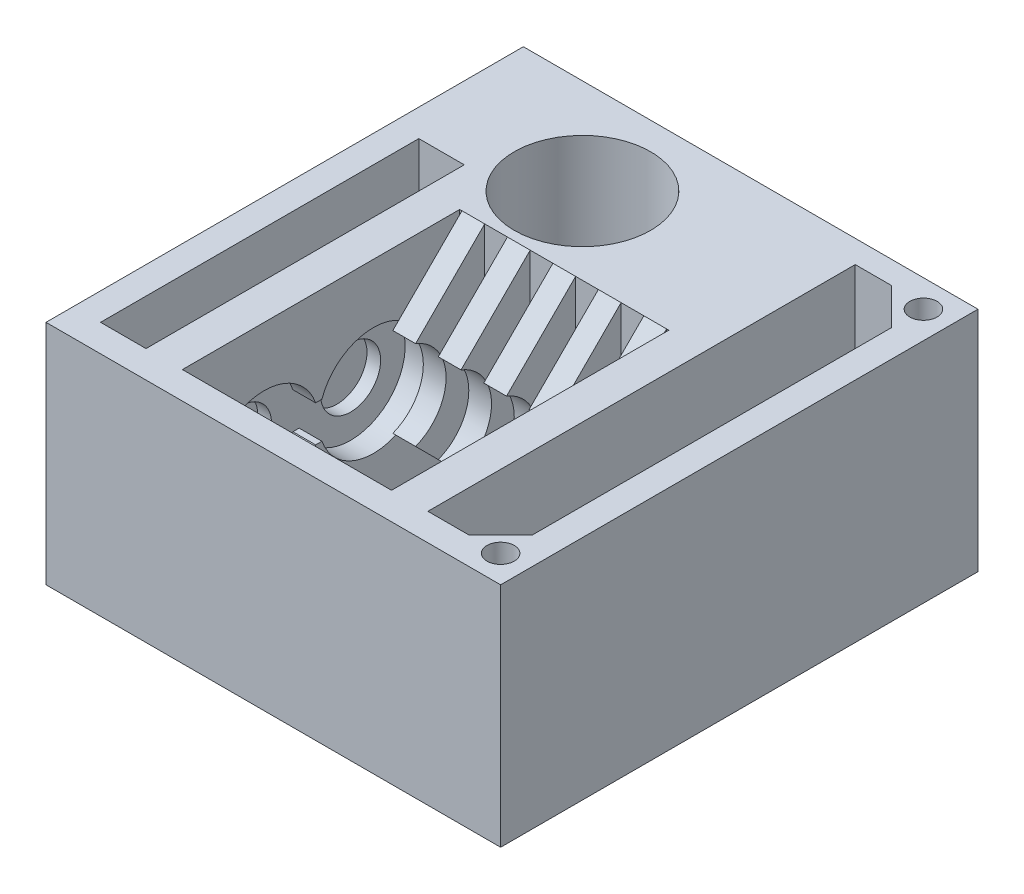
from build123d import *

# Parameters (mm, degrees)
SKETCH2_W           = 100
SKETCH2_H           = 105
BOSS_EXTRUDE1_DEPTH = 50
CUT_EXTRUDE1_REACH  = 52
SKETCH3_R           = 15
CUT_EXTRUDE3_REACH  = 52
SKETCH5_W           = 16
SKETCH5_H           = 80
SKETCH5_W_2         = 10
SKETCH5_H_2         = 70
CUT_EXTRUDE4_DEPTH  = 31
SKETCH7_R           = 6.6
BOSS_EXTRUDE2_DEPTH = 3
CUT_EXTRUDE7_REACH  = 52
SKETCH11_W          = 16
SKETCH11_H          = 14
CUT_EXTRUDE5_REACH  = 52
SKETCH8_W           = 46
SKETCH8_H           = 61
SKETCH9_R           = 1.75
CUT_EXTRUDE8_DEPTH  = 3
SKETCH13_W          = 20
SKETCH13_H          = 19
CUT_EXTRUDE9_DEPTH  = 30
BOSS_EXTRUDE4_DEPTH = 5
LPATTERN10_COUNT    = 5
LPATTERN10_PITCH    = 10
BOSS_EXTRUDE5_DEPTH = 5
LPATTERN11_COUNT    = 4
LPATTERN11_PITCH    = 10
BOSS_EXTRUDE6_DEPTH = 50
SKETCH20_R          = 3
CUT_EXTRUDE13_DEPTH = 50


with BuildPart() as part:
    # Sketch2 → Boss-Extrude1 (new body)
    with BuildSketch(Plane(origin=(0, 0, 0), x_dir=(1, 0, 0), z_dir=(0, 1, 0))):
        Rectangle(SKETCH2_W, SKETCH2_H)
    extrude(amount=BOSS_EXTRUDE1_DEPTH)

    # Sketch3 → Cut-Extrude1 (cut, up to next)
    with BuildSketch(Plane(origin=(0, 50, 0), x_dir=(1, 0, 0), z_dir=(0, 1, 0)), mode=Mode.PRIVATE) as cut_extrude1_sk1:
        with Locations((-16.005435425, 31.5)):
            Circle(SKETCH3_R)
    cut_extrude1_tool1 = extrude(cut_extrude1_sk1.sketch, amount=-CUT_EXTRUDE1_REACH, mode=Mode.PRIVATE) & part.part
    add(cut_extrude1_tool1.solids().sort_by_distance((-16.005435, 50, -31.5))[0], mode=Mode.SUBTRACT)

    # Sketch5 → Cut-Extrude3 (cut, up to next)
    with BuildSketch(Plane(origin=(0, 50, 0), x_dir=(1, 0, 0), z_dir=(0, 1, 0)), mode=Mode.PRIVATE) as cut_extrude3_sk1:
        with Locations((36, -6.5)):
            Rectangle(SKETCH5_W, SKETCH5_H)
    cut_extrude3_tool1 = extrude(cut_extrude3_sk1.sketch, amount=-CUT_EXTRUDE3_REACH, mode=Mode.PRIVATE) & part.part
    add(cut_extrude3_tool1.solids().sort_by_distance((36, 50, 6.5))[0], mode=Mode.SUBTRACT)
    # Sketch5 → Cut-Extrude3 (cut, up to next)
    with BuildSketch(Plane(origin=(0, 50, 0), x_dir=(1, 0, 0), z_dir=(0, 1, 0)), mode=Mode.PRIVATE) as cut_extrude3_sk2:
        with Locations((-39, -11.5)):
            Rectangle(SKETCH5_W_2, SKETCH5_H_2)
    cut_extrude3_tool2 = extrude(cut_extrude3_sk2.sketch, amount=-CUT_EXTRUDE3_REACH, mode=Mode.PRIVATE) & part.part
    add(cut_extrude3_tool2.solids().sort_by_distance((-39, 50, 11.5))[0], mode=Mode.SUBTRACT)

    # Sketch6 → Cut-Extrude4 (cut)
    with BuildSketch(Plane(origin=(28, 0, 0), x_dir=(0, 0, -1), z_dir=(1, 0, 0))):
        with BuildLine():
            Line((-17.186291501, 29), (-15.813708499, 29))
            ThreePointArc((-15.813708499, 29), (7.5, 25), (-15.813708499, 21))
            Line((-15.813708499, 21), (-17.186291501, 21))
            ThreePointArc((-17.186291501, 21), (-40.5, 25), (-17.186291501, 29))
        make_face()
    cut_extrude4 = extrude(amount=-CUT_EXTRUDE4_DEPTH, mode=Mode.SUBTRACT)

    # Sketch7 → Boss-Extrude2 (add)
    with BuildSketch(Plane(origin=(28, 0, 0), x_dir=(0, 0, -1), z_dir=(1, 0, 0))):
        with BuildLine():
            Line((-17.186291501, 21), (-15.813708499, 21))
            ThreePointArc((-15.813708499, 21), (7.5, 25), (-15.813708499, 29))
            Line((-15.813708499, 29), (-17.186291501, 29))
            ThreePointArc((-17.186291501, 29), (-40.5, 25), (-17.186291501, 21))
        make_face()
        with Locations((-28.5, 25)):
            Circle(SKETCH7_R, mode=Mode.SUBTRACT)
        with Locations((-4.5, 25)):
            Circle(SKETCH7_R, mode=Mode.SUBTRACT)
    boss_extrude2 = extrude(amount=-BOSS_EXTRUDE2_DEPTH)

    # Mirror1: Cut-Extrude4, Boss-Extrude2 across plane
    add(cut_extrude4.mirror(Plane(origin=(-3, 0, 0), x_dir=(0, 0, 1), z_dir=(1, 0, 0))), mode=Mode.SUBTRACT)
    add(boss_extrude2.mirror(Plane(origin=(-3, 0, 0), x_dir=(0, 0, 1), z_dir=(1, 0, 0))))

    # Sketch11 → Cut-Extrude7 (cut, up to next)
    with BuildSketch(Plane(origin=(0, 50, 0), x_dir=(1, 0, 0), z_dir=(0, 1, 0)), mode=Mode.PRIVATE) as cut_extrude7_sk1:
        with Locations((36, 40.5)):
            Rectangle(SKETCH11_W, SKETCH11_H)
    cut_extrude7_tool1 = extrude(cut_extrude7_sk1.sketch, amount=-CUT_EXTRUDE7_REACH, mode=Mode.PRIVATE) & part.part
    add(cut_extrude7_tool1.solids().sort_by_distance((36, 50, -40.5))[0], mode=Mode.SUBTRACT)

    # Sketch8 → Cut-Extrude5 (cut, up to next)
    with BuildSketch(Plane(origin=(0, 50, 0), x_dir=(1, 0, 0), z_dir=(0, 1, 0)), mode=Mode.PRIVATE) as cut_extrude5_sk1:
        with Locations((-3, -16)):
            Rectangle(SKETCH8_W, SKETCH8_H)
    cut_extrude5_tool1 = extrude(cut_extrude5_sk1.sketch, amount=-CUT_EXTRUDE5_REACH, mode=Mode.PRIVATE) & part.part
    add(cut_extrude5_tool1.solids().sort_by_distance((-3, 50, 16))[0], mode=Mode.SUBTRACT)

    # Sketch9 → Cut-Extrude8 (cut)
    with BuildSketch(Plane(origin=(28, 0, 0), x_dir=(0, 0, -1), z_dir=(1, 0, 0))):
        with Locations((19.5, 25)):
            Circle(SKETCH9_R)
    extrude(amount=-CUT_EXTRUDE8_DEPTH, mode=Mode.SUBTRACT)

    # Sketch13 → Cut-Extrude9 (cut)
    with BuildSketch(Plane.XZ):
        with Locations((15, -24)):
            Rectangle(SKETCH13_W, SKETCH13_H)
    extrude(amount=-CUT_EXTRUDE9_DEPTH, mode=Mode.SUBTRACT)

    # Sketch19 → Boss-Extrude6 (add)
    with BuildSketch(Plane(origin=(0, 50, 0), x_dir=(1, 0, 0), z_dir=(0, 1, 0))):
        Polygon((36, 47.5), (44, 47.5), (44, 39.5), align=None)
    boss_extrude6 = extrude(amount=-BOSS_EXTRUDE6_DEPTH)

    # Mirror2: Boss-Extrude6 across plane
    add(boss_extrude6.mirror(Plane.XY))

    # Sketch20 → Cut-Extrude13 (cut)
    with BuildSketch(Plane(origin=(0, 50, 0), x_dir=(1, 0, 0), z_dir=(0, 1, 0))):
        with Locations((44, 46.5)):
            Circle(SKETCH20_R)
        with Locations((44, -46.5)):
            Circle(SKETCH20_R)
    extrude(amount=-CUT_EXTRUDE13_DEPTH, mode=Mode.SUBTRACT)


with BuildPart() as body_2:
    # Sketch14 → Boss-Extrude4 (new body)
    with BuildSketch(Plane.ZY.offset(-19.5)):
        with BuildLine():
            Line((-14.5, 50), (-14.5, 0))
            Line((-14.5, 0), (0.708461146, 15.208461146))
            ThreePointArc((0.708461146, 15.208461146), (-6, 25), (0.708461146, 34.791538854))
            Line((0.708461146, 34.791538854), (-14.5, 50))
        make_face()
    boss_extrude4 = extrude(amount=BOSS_EXTRUDE4_DEPTH)


with BuildPart() as lpattern10_1:
    # LPattern10: Boss-Extrude4 ×5
    with Locations(*[(-i * LPATTERN10_PITCH, 0, 0) for i in range(1, LPATTERN10_COUNT)]):
        add(boss_extrude4)


with BuildPart() as body_7:
    # Sketch15 → Boss-Extrude5 (new body)
    with BuildSketch(Plane.ZY.offset(-14.5)):
        with BuildLine():
            Line((46.5, 0), (46.5, 50))
            Line((46.5, 50), (31.144102864, 34.644102864))
            ThreePointArc((31.144102864, 34.644102864), (38.5, 25), (31.144102864, 15.355897136))
            Line((31.144102864, 15.355897136), (46.5, 0))
        make_face()
    boss_extrude5 = extrude(amount=BOSS_EXTRUDE5_DEPTH)


with BuildPart() as lpattern11_1:
    # LPattern11: Boss-Extrude5 ×4
    with Locations(*[(-i * LPATTERN11_PITCH, 0, 0) for i in range(1, LPATTERN11_COUNT)]):
        add(boss_extrude5)


solid = Compound([part.part, body_2.part, lpattern10_1.part, body_7.part, lpattern11_1.part])
